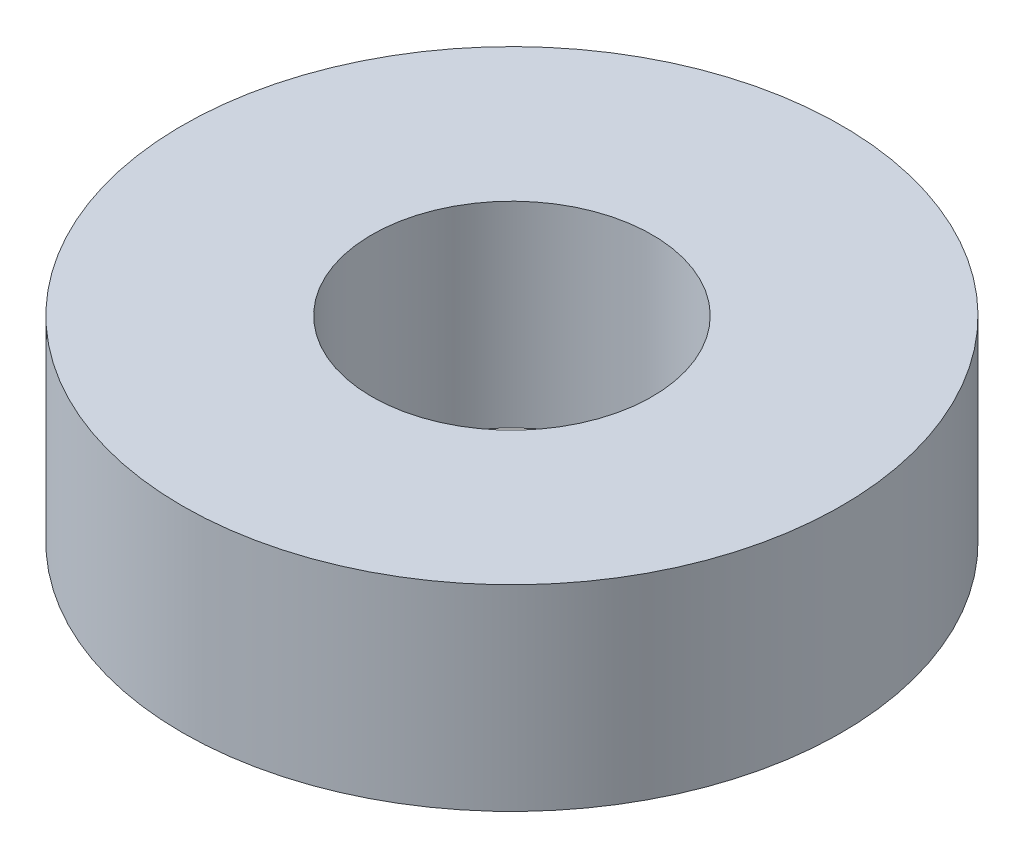
from build123d import *

# Parameters (mm, degrees)
SKETCH1_R           = 23.5
SKETCH1_R_2         = 10
BOSS_EXTRUDE1_DEPTH = 14


with BuildPart() as part:
    # Sketch1 → Boss-Extrude1 (new body)
    with BuildSketch(Plane(origin=(0, 0, 0), x_dir=(1, 0, 0), z_dir=(0, 1, 0))):
        Circle(SKETCH1_R)
        Circle(SKETCH1_R_2, mode=Mode.SUBTRACT)
    extrude(amount=BOSS_EXTRUDE1_DEPTH)


solid = part.part
